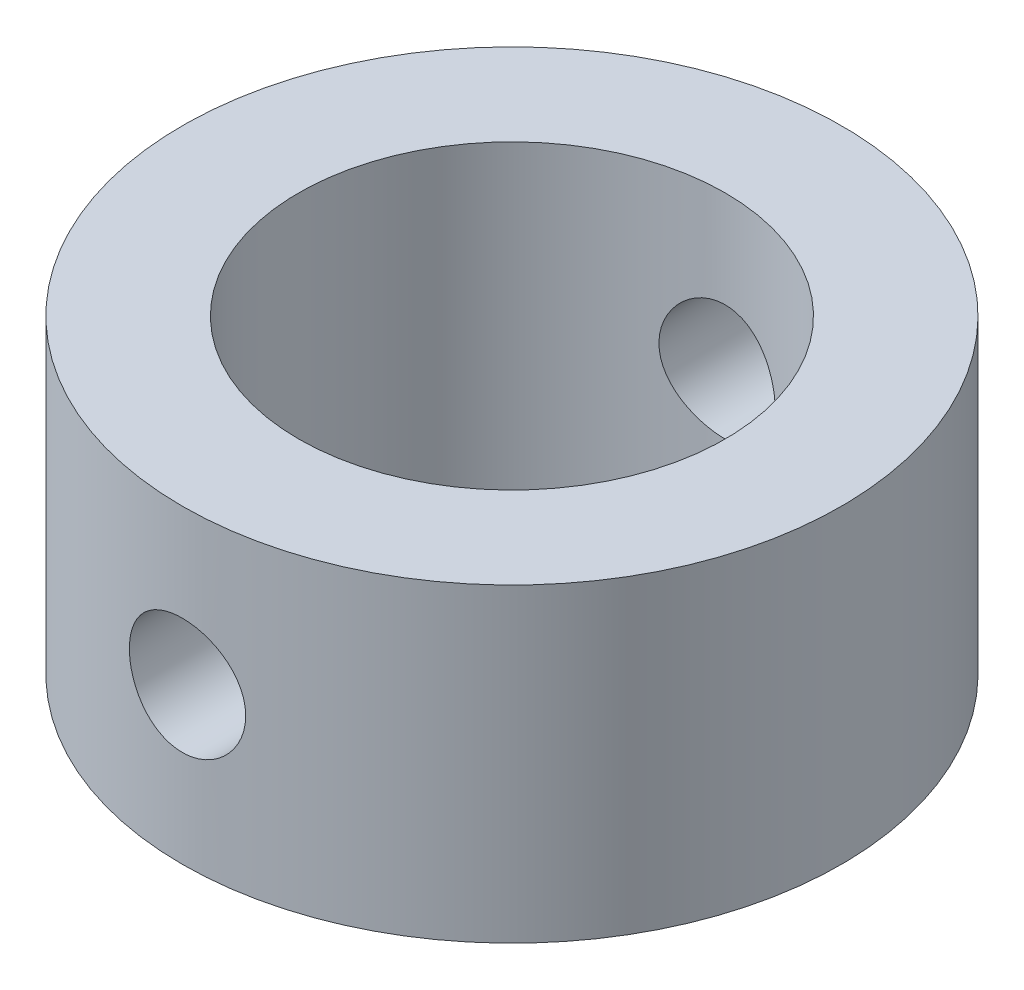
from build123d import *

# Parameters (mm, degrees)
SKETCH1_R               = 53.975
BOSS_EXTRUDE1_DEPTH     = 50.8
SKETCH2_R               = 34.925
CUT_EXTRUDE1_DEPTH      = 51.8
SKETCH4_R               = 9.525
CUT_EXTRUDE3_DEPTH      = 54.975
CUT_EXTRUDE3_DEPTH_BACK = 54.975


with BuildPart() as part:
    # Sketch1 → Boss-Extrude1 (new body)
    with BuildSketch(Plane(origin=(0, 0, 0), x_dir=(1, 0, 0), z_dir=(0, 1, 0))):
        Circle(SKETCH1_R)
    extrude(amount=BOSS_EXTRUDE1_DEPTH)

    # Sketch2 → Cut-Extrude1 (cut, through all)
    with BuildSketch(Plane(origin=(0, 50.8, 0), x_dir=(1, 0, 0), z_dir=(0, 1, 0))):
        Circle(SKETCH2_R)
    extrude(amount=-CUT_EXTRUDE1_DEPTH, mode=Mode.SUBTRACT)

    # Sketch4 → Cut-Extrude3 (cut, two sides)
    with BuildSketch(Plane.XY) as cut_extrude3_sk:
        with Locations((0, 25.4)):
            Circle(SKETCH4_R)
    extrude(amount=CUT_EXTRUDE3_DEPTH, mode=Mode.SUBTRACT)
    extrude(cut_extrude3_sk.sketch, amount=-CUT_EXTRUDE3_DEPTH_BACK, mode=Mode.SUBTRACT)


solid = part.part
